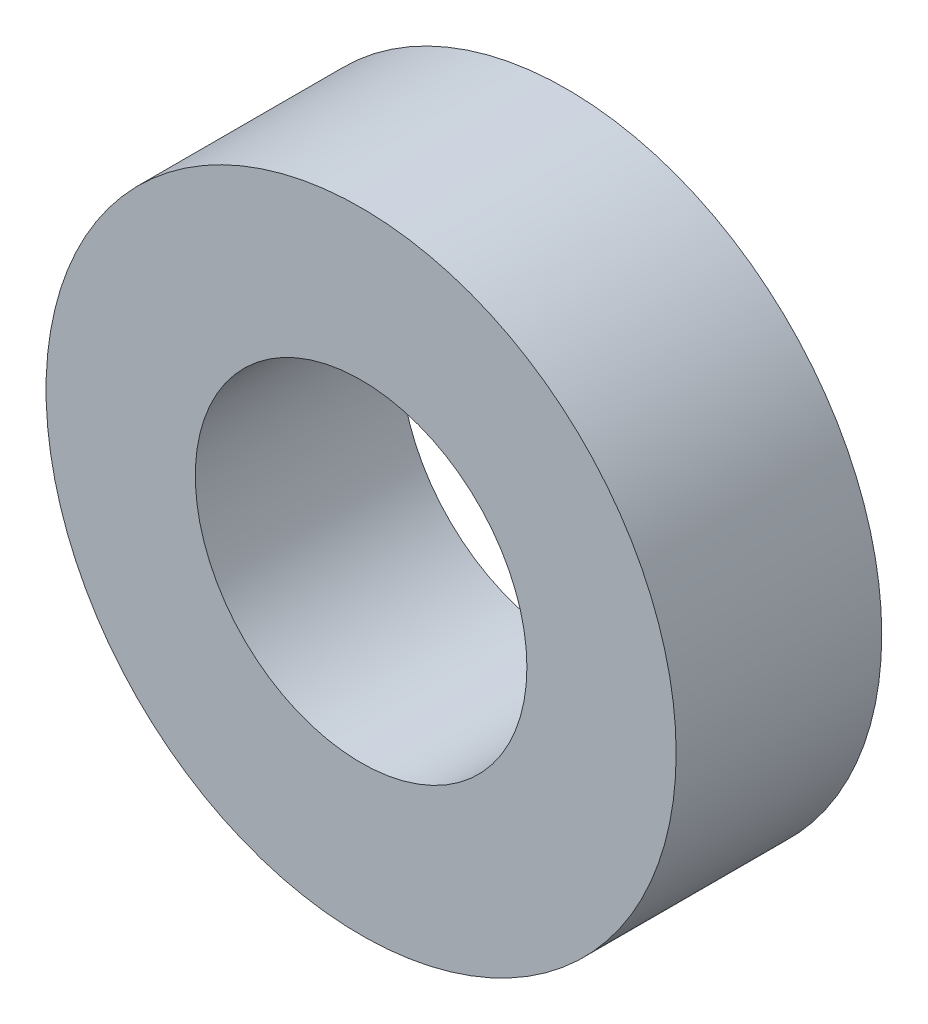
from build123d import *

# Parameters (mm, degrees)
SKETCH1_R          = 4.75
EXTRUDE1_DEPTH     = 3.1
SKETCH2_R          = 2.5
CUT_EXTRUDE1_DEPTH = 4.1


with BuildPart() as part:
    # Sketch1 → Extrude1 (new body)
    with BuildSketch(Plane.XY):
        Circle(SKETCH1_R)
    extrude(amount=-EXTRUDE1_DEPTH)

    # Sketch2 → Cut-Extrude1 (cut, through all)
    with BuildSketch(Plane.XY):
        Circle(SKETCH2_R)
    extrude(amount=-CUT_EXTRUDE1_DEPTH, mode=Mode.SUBTRACT)


solid = part.part
